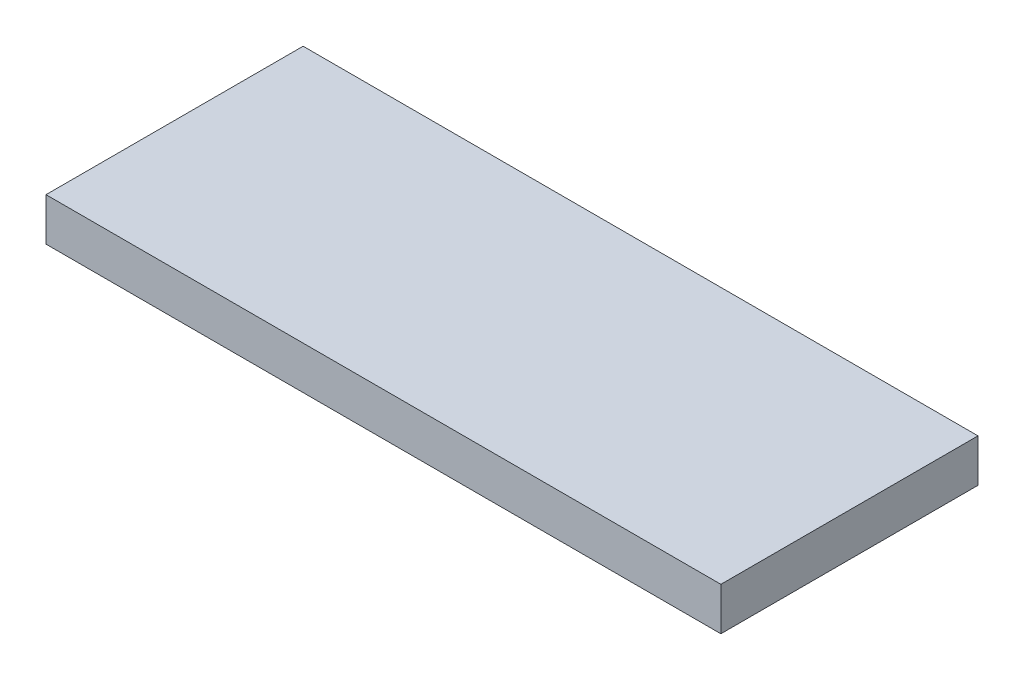
from build123d import *

# Parameters (mm, degrees)
SKETCH1_W           = 100
SKETCH1_H           = 38.1
SKETCH1_R           = 2.54
BOSS_EXTRUDE1_DEPTH = 6.35
SKETCH2_W           = 100
SKETCH2_H           = 38.1
BOSS_EXTRUDE2_DEPTH = 2.54


with BuildPart() as part:
    # Sketch1 → Boss-Extrude1 (new body)
    with BuildSketch(Plane(origin=(0, 0, 0), x_dir=(1, 0, 0), z_dir=(0, 1, 0))):
        with Locations((28.74, 0)):
            Rectangle(SKETCH1_W, SKETCH1_H)
        Circle(SKETCH1_R, mode=Mode.SUBTRACT)
        with Locations((57.48, 0)):
            Circle(SKETCH1_R, mode=Mode.SUBTRACT)
    extrude(amount=BOSS_EXTRUDE1_DEPTH)

    # Sketch2 → Boss-Extrude2 (add)
    with BuildSketch(Plane(origin=(0, 6.35, 0), x_dir=(1, 0, 0), z_dir=(0, 1, 0))):
        with Locations((28.74, 0)):
            Rectangle(SKETCH2_W, SKETCH2_H)
    extrude(amount=-BOSS_EXTRUDE2_DEPTH)


solid = part.part
